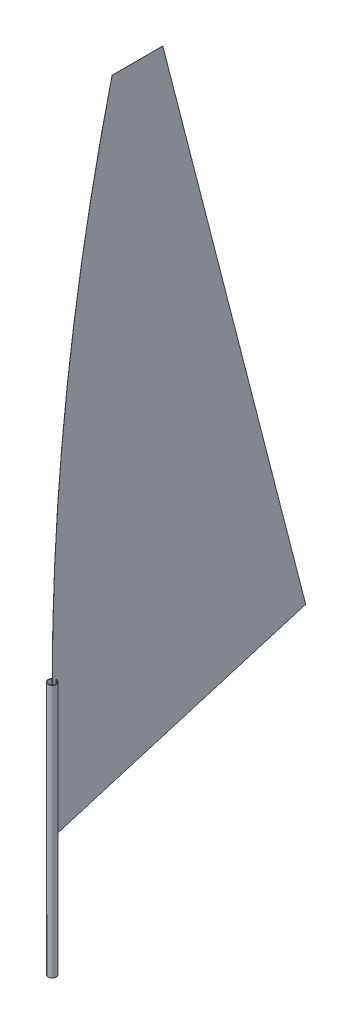
from build123d import *

# Parameters (mm, degrees)
SKETCH2_R                = 50
SKETCH2_R_2              = 44
BOSS_EXTRUDE1_DEPTH      = 2000
BOSS_EXTRUDE1_DEPTH_BACK = 1000
BOSS_EXTRUDE2_DEPTH      = 0.5


with BuildPart() as part:
    # Sketch2 → Boss-Extrude1 (new body, two sides)
    with BuildSketch(Plane(origin=(0, 0, 0), x_dir=(1, 0, 0), z_dir=(0, 1, 0))) as boss_extrude1_sk:
        Circle(SKETCH2_R)
        Circle(SKETCH2_R_2, mode=Mode.SUBTRACT)
    extrude(amount=BOSS_EXTRUDE1_DEPTH)
    extrude(boss_extrude1_sk.sketch, amount=-BOSS_EXTRUDE1_DEPTH_BACK)


with BuildPart() as body_2:
    # Sketch4 → Boss-Extrude2 (new body, symmetric)
    with BuildSketch(Plane(origin=(0, 0, 0), x_dir=(0, 0, -1), z_dir=(1, 0, 0))):
        with BuildLine():
            Line((0, 400), (3000, 1295.997925735))
            Line((3000, 1295.997925735), (1307.930468861, 7866.514210209))
            Line((1307.930468861, 7866.514210209), (707.930468861, 7866.514210209))
            ThreePointArc((707.930468861, 7866.514210209), (177.622273407, 4954.536957263), (0, 2000))
            Line((0, 2000), (0, 400))
        make_face()
    extrude(amount=BOSS_EXTRUDE2_DEPTH, both=True)


solid = Compound([part.part, body_2.part])
